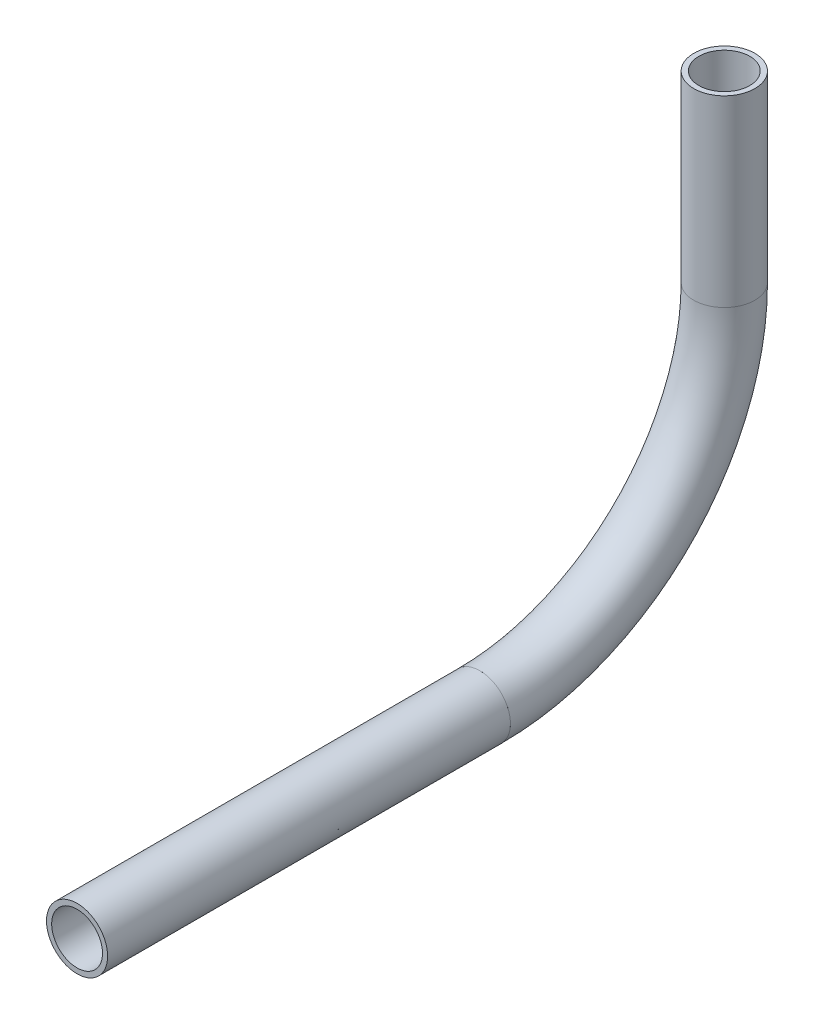
from build123d import *

# Parameters (mm, degrees)
SKETCH1_R                 = 6.35
SKETCH1_R_2               = 5.2832
PIPE_0_5_SCH_40_1_DEPTH   = 38.1
SKETCH1_ON_SEGMENT_2_R    = 6.35
SKETCH1_ON_SEGMENT_2_R_2  = 5.2832
PIPE_0_5_SCH_40_1_2_ANGLE = 90
SKETCH1_ON_SEGMENT_3_R    = 6.35
SKETCH1_ON_SEGMENT_3_R_2  = 5.2832
PIPE_0_5_SCH_40_1_3_DEPTH = 83.711153487


with BuildPart() as part:
    # Sketch1 → Pipe 0.5 SCH 40(1) (new body)
    with BuildSketch(Plane(origin=(0, -191.160399283, 259.179579455), x_dir=(0, 0, -1), z_dir=(0, -1, 0))):
        Circle(SKETCH1_R)
        Circle(SKETCH1_R_2, mode=Mode.SUBTRACT)
    extrude(amount=PIPE_0_5_SCH_40_1_DEPTH)


with BuildPart() as body_2:
    # Sketch1 on segment 2 (carried to the start of arc 2) → Pipe 0.5 SCH 40_1 2 (revolve)
    with BuildSketch(Plane(origin=(0, -229.260399283, 259.179579455), x_dir=(0, 0, -1), z_dir=(0, -1, 0))):
        Circle(SKETCH1_ON_SEGMENT_2_R)
        Circle(SKETCH1_ON_SEGMENT_2_R_2, mode=Mode.SUBTRACT)
    revolve(axis=Axis((0, -229.260399283, 309.979579455), (-1, 0, 0)), revolution_arc=PIPE_0_5_SCH_40_1_2_ANGLE)


with BuildPart() as body_3:
    # Sketch1 on segment 3 (carried to segment 3) → Pipe 0.5 SCH 40_1 3 (new body)
    with BuildSketch(Plane(origin=(0, -280.060399283, 309.979579455), x_dir=(0, -1, 0), z_dir=(0, 0, 1))):
        Circle(SKETCH1_ON_SEGMENT_3_R)
        Circle(SKETCH1_ON_SEGMENT_3_R_2, mode=Mode.SUBTRACT)
    extrude(amount=PIPE_0_5_SCH_40_1_3_DEPTH)


solid = Compound([part.part, body_2.part, body_3.part])
